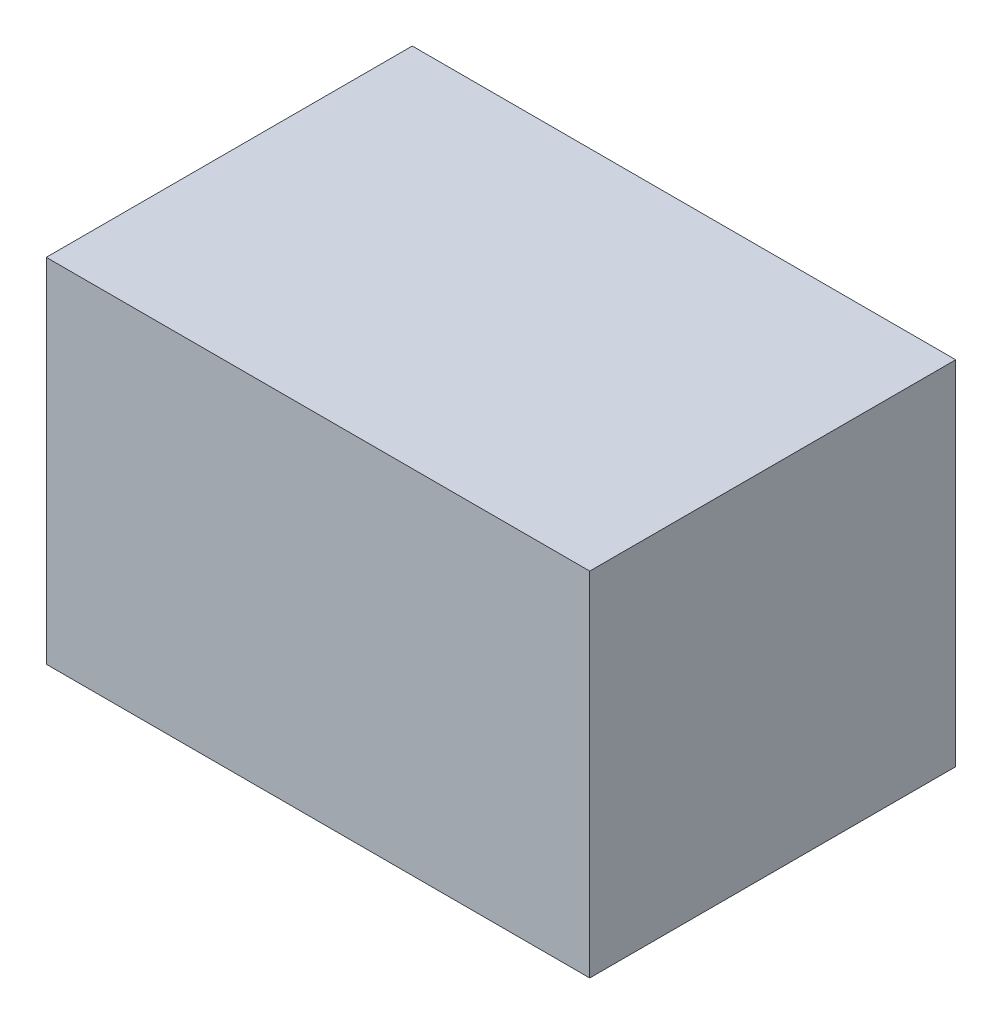
from build123d import *

# Parameters (mm, degrees)
SKIZZE1_W                       = 118.790575329
SKIZZE1_H                       = 77.02826369
AUFSATZ_LINEAR_AUSTRAGEN1_DEPTH = 80


with BuildPart() as part:
    # Skizze1 → Aufsatz-Linear austragen1 (new body)
    with BuildSketch(Plane.XY):
        with Locations((-59.395287665, 38.514131845)):
            Rectangle(SKIZZE1_W, SKIZZE1_H)
    extrude(amount=AUFSATZ_LINEAR_AUSTRAGEN1_DEPTH)


solid = part.part
